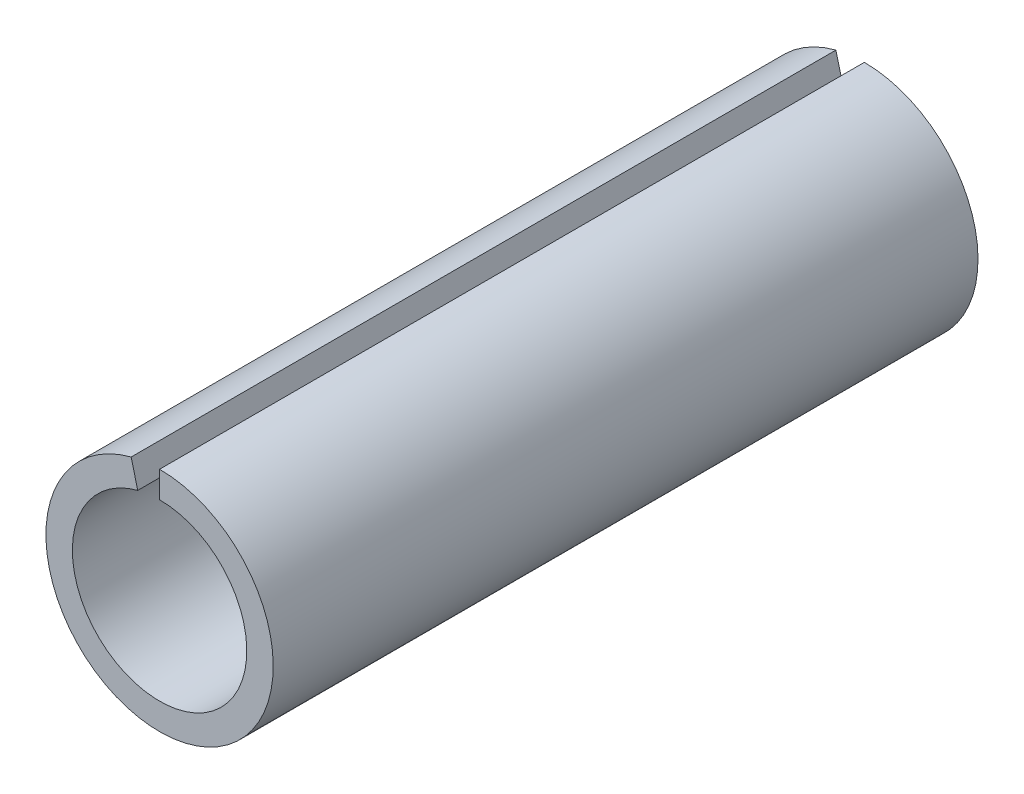
from build123d import *

# Parameters (mm, degrees)
BOSS_EXTRU_1_DEPTH = 40


with BuildPart() as part:
    # Esquisse1 → Boss.-Extru.1 (new body)
    with BuildSketch(Plane.XY):
        with BuildLine():
            Line((-1.614446605, 6.244682711), (-1.238993906, 4.792430918))
            ThreePointArc((-1.238993906, 4.792430918), (0.624486572, -4.910449727), (0, 4.95))
            Line((0, 4.95), (0, 6.45))
            ThreePointArc((0, 6.45), (0.813724927, -6.398464796), (-1.614446605, 6.244682711))
        make_face()
    extrude(amount=BOSS_EXTRU_1_DEPTH)


solid = part.part
